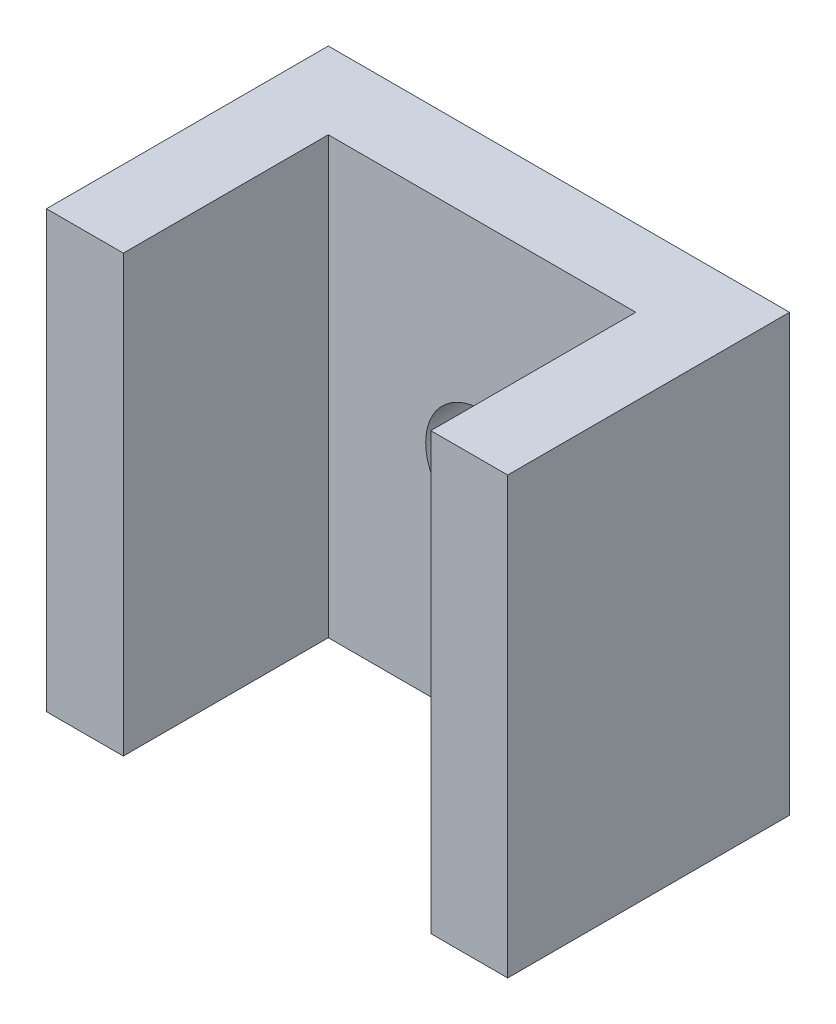
from build123d import *

# Parameters (mm, degrees)
BOSS_EXTRUDE1_DEPTH = 17
SKETCH2_R           = 2.2
CUT_EXTRUDE1_DEPTH  = 17


with BuildPart() as part:
    # Sketch1 → Boss-Extrude1 (new body)
    with BuildSketch(Plane(origin=(0, 0, 0), x_dir=(1, 0, 0), z_dir=(0, 1, 0))):
        Polygon((0, 0), (0, 11), (18, 11), (18, 0), (15, 0), (15, 8), (3, 8), (3, 0), align=None)
    extrude(amount=BOSS_EXTRUDE1_DEPTH)

    # Sketch2 → Cut-Extrude1 (cut)
    with BuildSketch(Plane(origin=(0, 0, -11), x_dir=(-1, 0, 0), z_dir=(0, 0, -1))):
        with Locations((-9, 8.5)):
            Circle(SKETCH2_R)
    extrude(amount=-CUT_EXTRUDE1_DEPTH, mode=Mode.SUBTRACT)


solid = part.part
